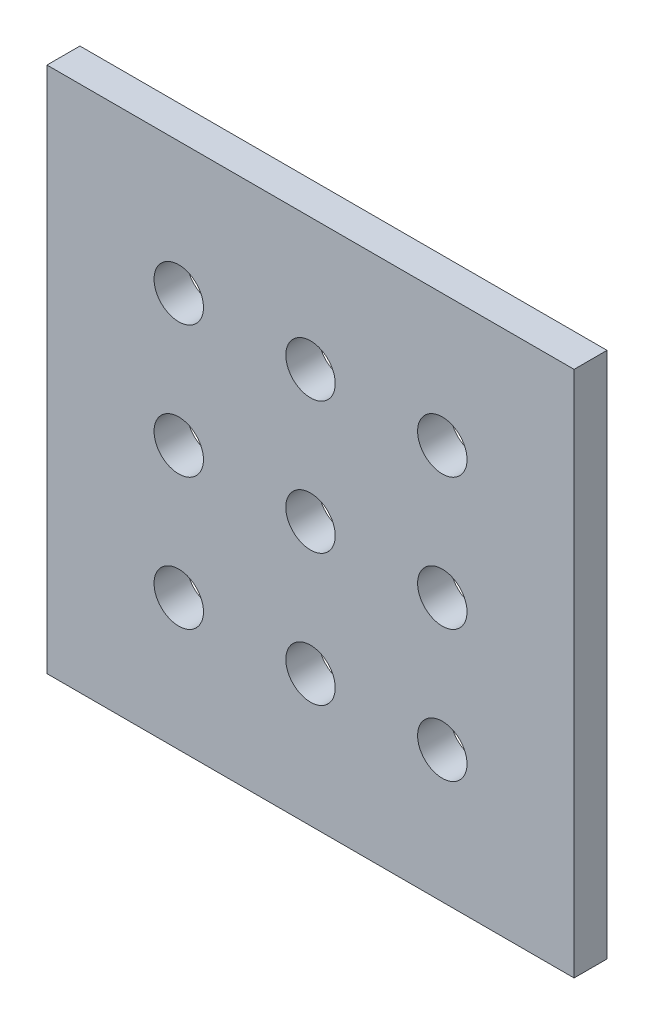
from build123d import *

# Parameters (mm, degrees)
SKETCH1_W           = 50.8
SKETCH1_H           = 50.8
SKETCH1_R           = 2.38125
BOSS_EXTRUDE1_DEPTH = 3.175


with BuildPart() as part:
    # Sketch1 → Boss-Extrude1 (new body)
    with BuildSketch(Plane.XY):
        with Locations((-25.4, 25.4)):
            Rectangle(SKETCH1_W, SKETCH1_H)
        with Locations((-12.7, 12.7)):
            Circle(SKETCH1_R, mode=Mode.SUBTRACT)
        with Locations((-25.4, 12.7)):
            Circle(SKETCH1_R, mode=Mode.SUBTRACT)
        with Locations((-38.1, 12.7)):
            Circle(SKETCH1_R, mode=Mode.SUBTRACT)
        with Locations((-25.4, 25.4)):
            Circle(SKETCH1_R, mode=Mode.SUBTRACT)
        with Locations((-38.1, 25.4)):
            Circle(SKETCH1_R, mode=Mode.SUBTRACT)
        with Locations((-25.4, 38.1)):
            Circle(SKETCH1_R, mode=Mode.SUBTRACT)
        with Locations((-38.1, 38.1)):
            Circle(SKETCH1_R, mode=Mode.SUBTRACT)
        with Locations((-12.7, 25.4)):
            Circle(SKETCH1_R, mode=Mode.SUBTRACT)
        with Locations((-12.7, 38.1)):
            Circle(SKETCH1_R, mode=Mode.SUBTRACT)
    extrude(amount=BOSS_EXTRUDE1_DEPTH)


solid = part.part
